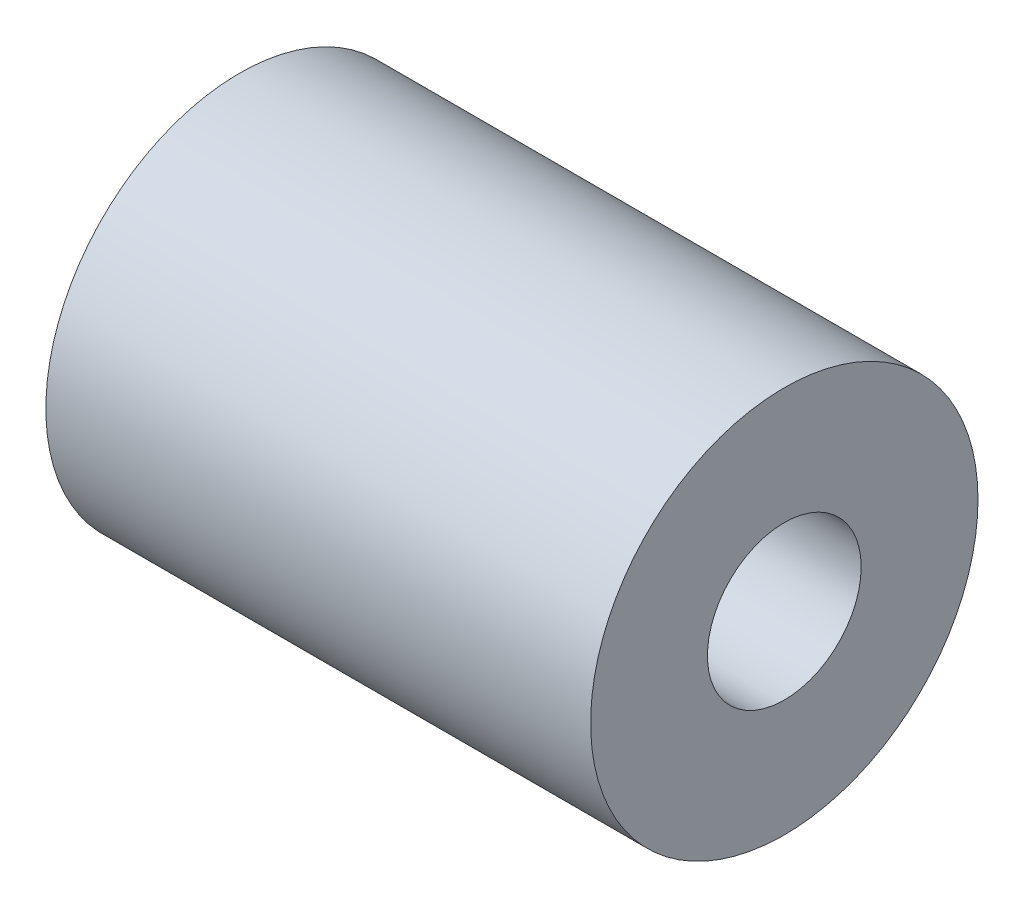
from build123d import *

# Parameters (mm, degrees)
SKETCH1_R                = 8
SKETCH1_R_2              = 2.5
BOSS_EXTRUDE1_DEPTH      = 11.25
SKETCH2_R                = 3.175
CUT_EXTRUDE1_DEPTH       = 11.25
SKETCH3_R                = 8
BOSS_EXTRUDE2_DEPTH      = 4.9
BOSS_EXTRUDE2_DEPTH_BACK = 4.9


with BuildPart() as part:
    # Sketch1 → Boss-Extrude1 (new body, symmetric)
    with BuildSketch(Plane(origin=(0, 0, 0), x_dir=(0, 0, -1), z_dir=(1, 0, 0))):
        Circle(SKETCH1_R)
        Circle(SKETCH1_R_2, mode=Mode.SUBTRACT)
    extrude(amount=BOSS_EXTRUDE1_DEPTH, both=True)

    # Sketch2 → Cut-Extrude1 (cut)
    with BuildSketch(Plane(origin=(11.25, 0, 0), x_dir=(0, 0, -1), z_dir=(1, 0, 0))):
        Circle(SKETCH2_R)
    extrude(amount=-CUT_EXTRUDE1_DEPTH, mode=Mode.SUBTRACT)

    # Sketch3 → Boss-Extrude2 (add, two sides)
    with BuildSketch(Plane(origin=(0, 0, 0), x_dir=(0, 0, -1), z_dir=(1, 0, 0))) as boss_extrude2_sk:
        Circle(SKETCH3_R)
    extrude(amount=BOSS_EXTRUDE2_DEPTH)
    extrude(boss_extrude2_sk.sketch, amount=-BOSS_EXTRUDE2_DEPTH_BACK)


solid = part.part
